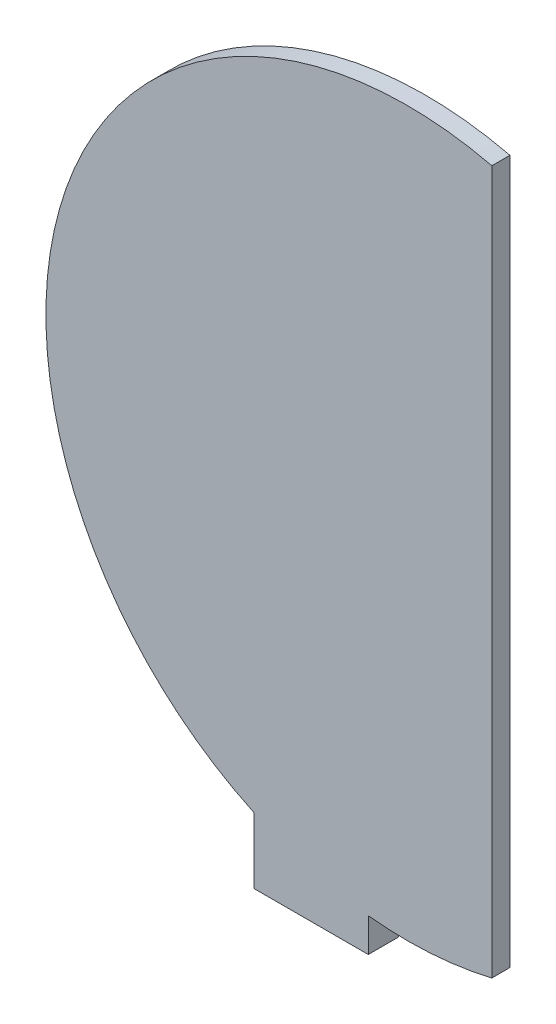
from build123d import *

# Parameters (mm, degrees)
BOSS_EXTRUDE1_DEPTH = 3
SKETCH2_W           = 19
SKETCH2_H           = 24.344098819
BOSS_EXTRUDE2_DEPTH = 5


with BuildPart() as part:
    # Sketch1 → Boss-Extrude1 (new body)
    with BuildSketch(Plane.XY):
        with BuildLine():
            Line((11.419301697, 73.454544617), (11.419301697, -43.242123234))
            ThreePointArc((11.419301697, -43.242123234), (-62.561825873, 15.106210692), (11.419301697, 73.454544617))
        make_face()
    extrude(amount=BOSS_EXTRUDE1_DEPTH)

    # Sketch2 → Boss-Extrude2 (add)
    with BuildSketch(Plane.XY.offset(3)):
        with Locations((-18.580698303, -37.949042382)):
            Rectangle(SKETCH2_W, SKETCH2_H)
    extrude(amount=-BOSS_EXTRUDE2_DEPTH)


solid = part.part
